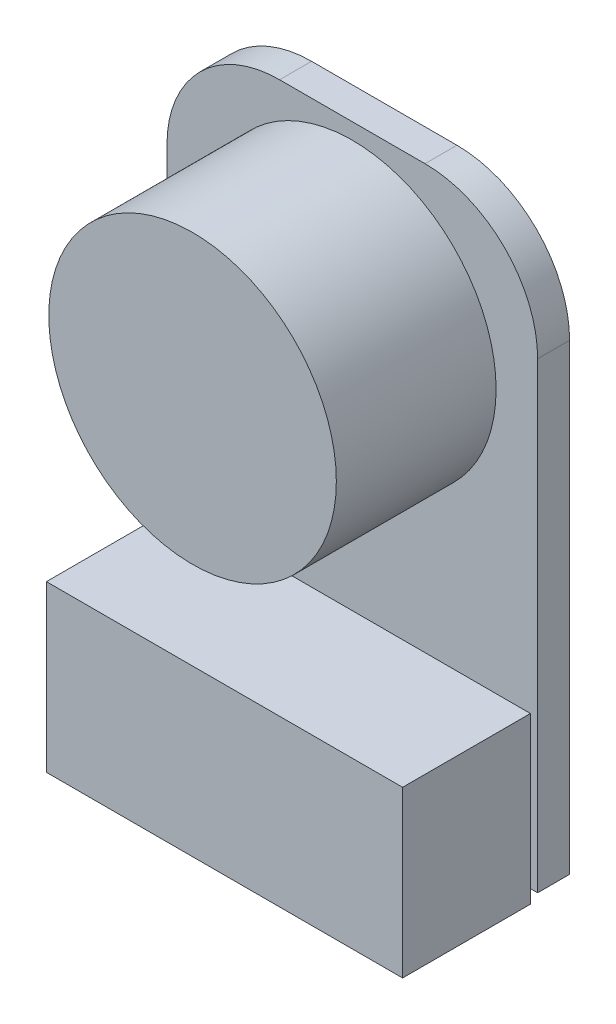
from build123d import *

# Parameters (mm, degrees)
EXTRUDE_1_DEPTH = 1
SKETCH_2_R      = 4.5
EXTRUDE_2_DEPTH = 5
SKETCH_3_W      = 11.148375858
SKETCH_3_H      = 5.169406936
EXTRUDE_3_DEPTH = 4


with BuildPart() as part:
    # 草图1 → 凸台-拉伸1 (new body)
    with BuildSketch(Plane.XY):
        with BuildLine():
            Line((-2.275007411, 5), (2.275007411, 5))
            ThreePointArc((2.275007411, 5), (4.76799478, 3.967370821), (5.800623959, 1.474383452))
            Line((5.800623959, 1.474383452), (5.800623959, -13))
            Line((5.800623959, -13), (-5.800623959, -13))
            Line((-5.800623959, -13), (-5.800623959, 1.474383452))
            ThreePointArc((-5.800623959, 1.474383452), (-4.76799478, 3.967370821), (-2.275007411, 5))
        make_face()
    extrude(amount=EXTRUDE_1_DEPTH)

    # 草图2 → 凸台-拉伸2 (add)
    with BuildSketch(Plane.XY.offset(1)):
        Circle(SKETCH_2_R)
    extrude(amount=EXTRUDE_2_DEPTH)

    # 草图3 → 凸台-拉伸3 (add)
    with BuildSketch(Plane.XY.offset(1)):
        with Locations((0, -10.837924987)):
            Rectangle(SKETCH_3_W, SKETCH_3_H)
    extrude(amount=EXTRUDE_3_DEPTH)


solid = part.part
